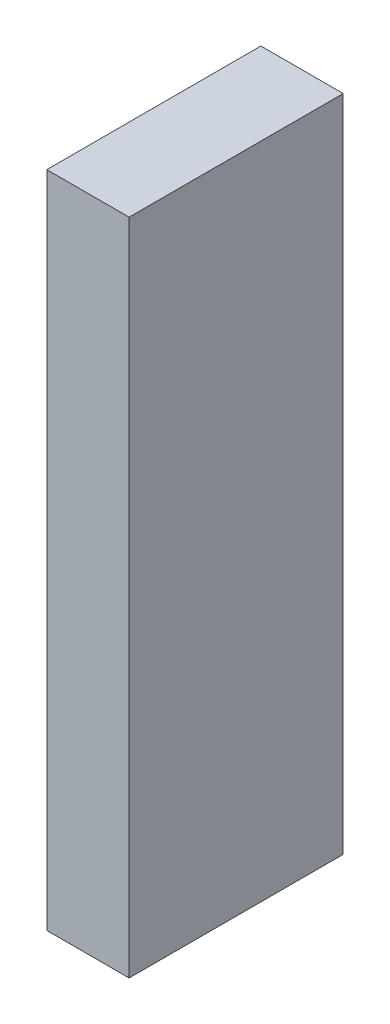
from build123d import *

# Parameters (mm, degrees)
SKETCH1_W           = 8.255
SKETCH1_H           = 25.4
BOSS_EXTRUDE1_DEPTH = 3.175


with BuildPart() as part:
    # Sketch1 → Boss-Extrude1 (new body)
    with BuildSketch(Plane(origin=(0, 0, 0), x_dir=(0, 0, -1), z_dir=(1, 0, 0))):
        Rectangle(SKETCH1_W, SKETCH1_H)
    extrude(amount=BOSS_EXTRUDE1_DEPTH)


solid = part.part
